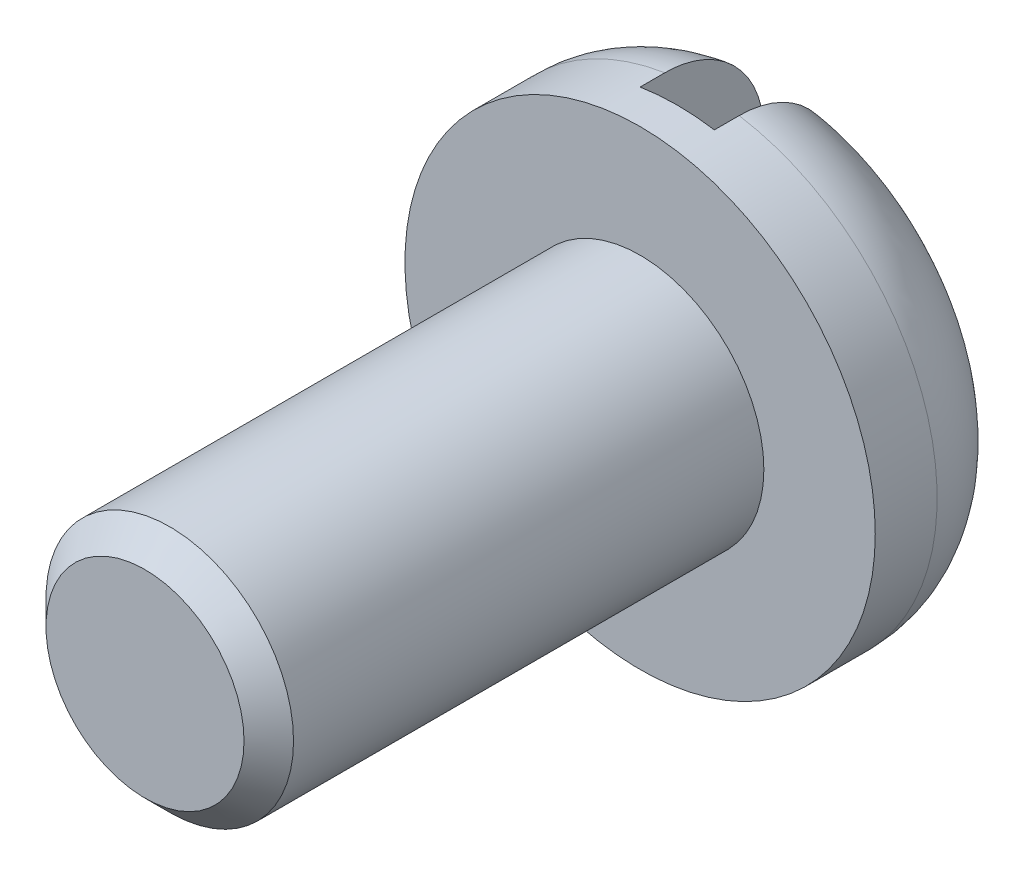
from build123d import *

# Parameters (mm, degrees)
ESQUISSE1_R                  = 1.9
BASE_EXTRUSION_DEPTH         = 1.3
CONG_1_R                     = 0.8
ESQUISSE2_R                  = 1
BOSS_EXTRU_1_DEPTH           = 4
CHANFREIN1_SIZE              = 0.2
ESQUISSE3_W                  = 0.6
ESQUISSE3_H                  = 1
ENL_V_MAT_EXTRU_1_DEPTH      = 2.9
ENL_V_MAT_EXTRU_1_DEPTH_BACK = 2.9


with BuildPart() as part:
    # Esquisse1 → Base-Extrusion (new body)
    with BuildSketch(Plane.XY):
        Circle(ESQUISSE1_R)
    extrude(amount=BASE_EXTRUSION_DEPTH)

    # Cong_1
    cong_1_edges = [part.edges().sort_by_distance(p)[0] for p in [
        (-1.9, 0, 0),
    ]]
    fillet(cong_1_edges, radius=CONG_1_R)

    # Esquisse2 → Boss.-Extru.1 (add)
    with BuildSketch(Plane.XY.offset(1.3)):
        Circle(ESQUISSE2_R)
    extrude(amount=BOSS_EXTRU_1_DEPTH)

    # Chanfrein1
    chanfrein1_edges = [part.edges().sort_by_distance(p)[0] for p in [
        (-1, 0, 5.3),
    ]]
    chamfer(chanfrein1_edges, length=CHANFREIN1_SIZE)

    # Esquisse3 → Enl_v. mat.-Extru.1 (cut, two sides)
    with BuildSketch(Plane(origin=(0, 0, 0), x_dir=(1, 0, 0), z_dir=(0, 1, 0))) as enl_v_mat_extru_1_sk:
        with Locations((0, -0.5)):
            Rectangle(ESQUISSE3_W, ESQUISSE3_H)
    extrude(amount=ENL_V_MAT_EXTRU_1_DEPTH, mode=Mode.SUBTRACT)
    extrude(enl_v_mat_extru_1_sk.sketch, amount=-ENL_V_MAT_EXTRU_1_DEPTH_BACK, mode=Mode.SUBTRACT)


solid = part.part
